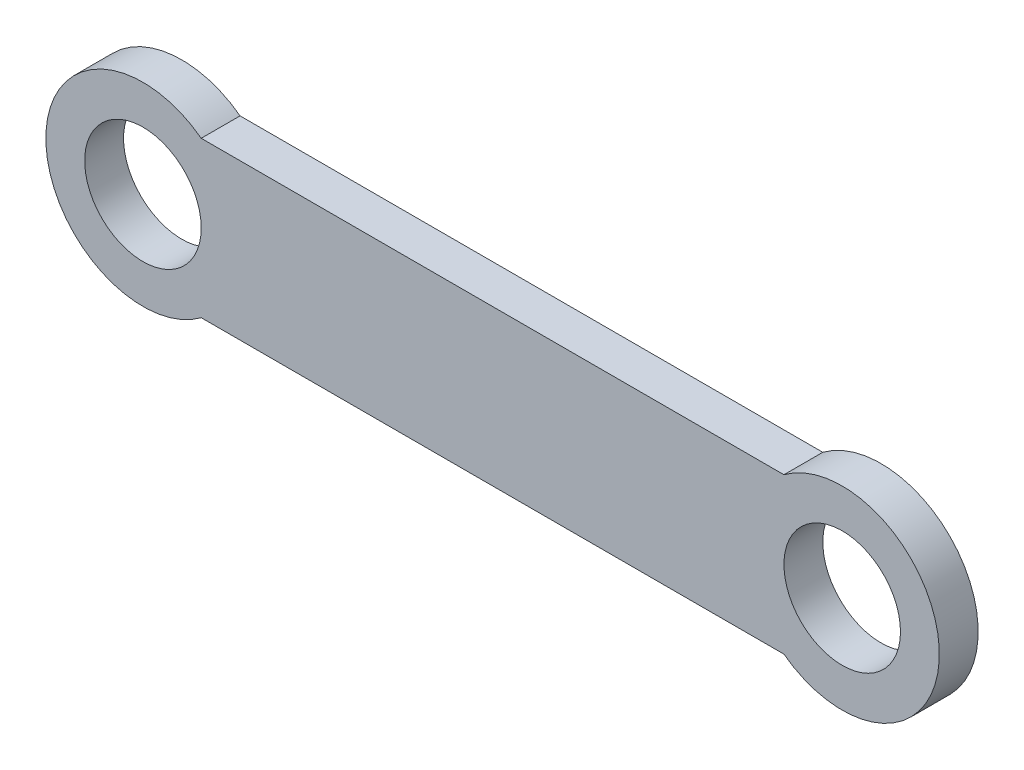
from build123d import *

# Parameters (mm, degrees)
SKETCH_1_R      = 1.5
EXTRUDE_1_DEPTH = 1


with BuildPart() as part:
    # 草图1 → 凸台-拉伸1 (new body)
    with BuildSketch(Plane.XY):
        with BuildLine():
            Line((-29.935577952, 0.5), (-14.935577952, 0.5))
            ThreePointArc((-14.935577952, 0.5), (-10.935577952, -1.5), (-14.935577952, -3.5))
            Line((-14.935577952, -3.5), (-29.935577952, -3.5))
            ThreePointArc((-29.935577952, -3.5), (-33.935577952, -1.5), (-29.935577952, 0.5))
        make_face()
        with Locations((-31.435577952, -1.5)):
            Circle(SKETCH_1_R, mode=Mode.SUBTRACT)
        with Locations((-13.435577952, -1.5)):
            Circle(SKETCH_1_R, mode=Mode.SUBTRACT)
    extrude(amount=EXTRUDE_1_DEPTH)


solid = part.part
